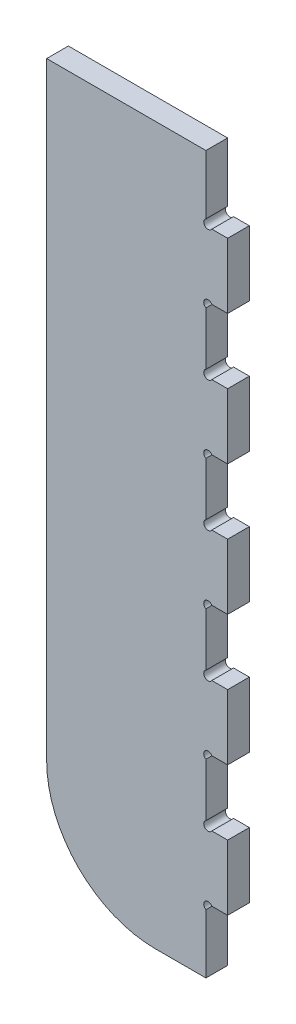
from build123d import *

# Parameters (mm, degrees)
BOSS_EXTRUDE1_DEPTH = 12


with BuildPart() as part:
    # Sketch1 → Boss-Extrude1 (new body)
    with BuildSketch(Plane.XY):
        with BuildLine():
            Line((36.538461538, -42.187912088), (27.803617527, -42.187912088))
            ThreePointArc((27.803617527, -42.187912088), (24.032111316, -41.72295633), (24.538461538, -45.489128447))
            Line((24.538461538, -45.489128447), (24.538461538, -78.187912088))
            Line((24.538461538, -78.187912088), (-3.461538462, -78.187912088))
            ThreePointArc((-3.461538462, -78.187912088), (-45.887945333, -60.614318959), (-63.461538462, -18.187912088))
            Line((-63.461538462, -18.187912088), (-63.461538462, 317.812087912))
            Line((-63.461538462, 317.812087912), (24.538461538, 317.812087912))
            Line((24.538461538, 317.812087912), (24.538461538, 285.113304271))
            ThreePointArc((24.538461538, 285.113304271), (24.032111316, 281.347132154), (27.803617527, 281.812087912))
            Line((27.803617527, 281.812087912), (36.538461538, 281.812087912))
            Line((36.538461538, 281.812087912), (36.538461538, 245.812087912))
            Line((36.538461538, 245.812087912), (27.803617527, 245.812087912))
            ThreePointArc((27.803617527, 245.812087912), (24.032111316, 246.27704367), (24.538461538, 242.510871553))
            Line((24.538461538, 242.510871553), (24.538461538, 213.113304271))
            ThreePointArc((24.538461538, 213.113304271), (24.032111316, 209.347132154), (27.803617527, 209.812087912))
            Line((27.803617527, 209.812087912), (36.538461538, 209.812087912))
            Line((36.538461538, 209.812087912), (36.538461538, 173.812087912))
            Line((36.538461538, 173.812087912), (27.803617527, 173.812087912))
            ThreePointArc((27.803617527, 173.812087912), (24.032111316, 174.27704367), (24.538461538, 170.510871553))
            Line((24.538461538, 170.510871553), (24.538461538, 164.212087912))
            Line((24.538461538, 164.212087912), (24.538461538, 141.113304271))
            ThreePointArc((24.538461538, 141.113304271), (24.032111316, 137.347132154), (27.803617527, 137.812087912))
            Line((27.803617527, 137.812087912), (36.538461538, 137.812087912))
            Line((36.538461538, 137.812087912), (36.538461538, 119.812087912))
            Line((36.538461538, 119.812087912), (36.538461538, 101.812087912))
            Line((36.538461538, 101.812087912), (27.803617527, 101.812087912))
            ThreePointArc((27.803617527, 101.812087912), (24.032111316, 102.27704367), (24.538461538, 98.510871553))
            Line((24.538461538, 98.510871553), (24.538461538, 75.412087912))
            Line((24.538461538, 75.412087912), (24.538461538, 69.113304271))
            ThreePointArc((24.538461538, 69.113304271), (24.032111316, 65.347132154), (27.803617527, 65.812087912))
            Line((27.803617527, 65.812087912), (36.538461538, 65.812087912))
            Line((36.538461538, 65.812087912), (36.538461538, 29.812087912))
            Line((36.538461538, 29.812087912), (27.803617527, 29.812087912))
            ThreePointArc((27.803617527, 29.812087912), (24.032111316, 30.27704367), (24.538461538, 26.510871553))
            Line((24.538461538, 26.510871553), (24.538461538, -2.886695729))
            ThreePointArc((24.538461538, -2.886695729), (24.032111316, -6.652867846), (27.803617527, -6.187912088))
            Line((27.803617527, -6.187912088), (36.538461538, -6.187912088))
            Line((36.538461538, -6.187912088), (36.538461538, -42.187912088))
        make_face()
    extrude(amount=BOSS_EXTRUDE1_DEPTH)


solid = part.part
